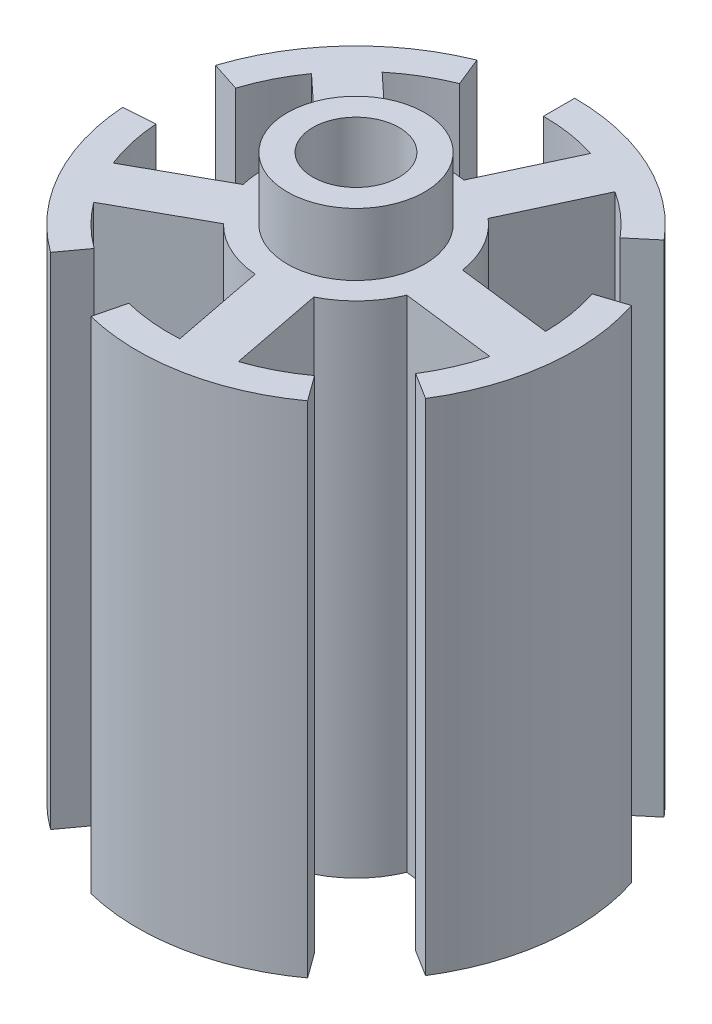
from build123d import *

# Parameters (mm, degrees)
BOSS_EXTRUDE2_DEPTH   = 40
BOSS_EXTRUDE2_2_DEPTH = 40
BOSS_EXTRUDE2_3_DEPTH = 40
BOSS_EXTRUDE2_4_DEPTH = 40
BOSS_EXTRUDE2_5_DEPTH = 40
BOSS_EXTRUDE3_DEPTH   = 40
SKETCH3_R             = 7.5
BOSS_EXTRUDE4_DEPTH   = 40
SKETCH5_R             = 5.5
BOSS_EXTRUDE5_DEPTH   = 5
SKETCH4_R             = 3.45
CUT_EXTRUDE1_DEPTH    = 45


with BuildPart() as part:
    # Sketch1 → Boss-Extrude2 (new body)
    with BuildSketch(Plane(origin=(0, 0, 0), x_dir=(1, 0, 0), z_dir=(0, 1, 0))):
        with BuildLine():
            Line((0, 17.5), (0, 15))
            ThreePointArc((0, 15), (6.339273926, 13.594616806), (11.490666647, 9.641814145))
            Line((11.490666647, 9.641814145), (13.405777755, 11.24878317))
            ThreePointArc((13.405777755, 11.24878317), (7.39581958, 15.860386273), (0, 17.5))
        make_face()
    extrude(amount=BOSS_EXTRUDE2_DEPTH)



with BuildPart() as body_2:
    # Sketch1 → Boss-Extrude2 2 (new body)
    with BuildSketch(Plane(origin=(0, 0, 0), x_dir=(1, 0, 0), z_dir=(0, 1, 0))):
        with BuildLine():
            Line((16.643489035, 5.407797402), (14.265847744, 4.635254916))
            ThreePointArc((14.265847744, 4.635254916), (14.888192275, -1.828040151), (12.720721442, -7.948788963))
            Line((12.720721442, -7.948788963), (14.840841683, -9.273587124))
            ThreePointArc((14.840841683, -9.273587124), (17.369557654, -2.13271351), (16.643489035, 5.407797402))
        make_face()
    extrude(amount=BOSS_EXTRUDE2_2_DEPTH)


with BuildPart() as body_3:
    # Sketch1 → Boss-Extrude2 3 (new body)
    with BuildSketch(Plane(origin=(0, 0, 0), x_dir=(1, 0, 0), z_dir=(0, 1, 0))):
        with BuildLine():
            Line((10.286241915, -14.157797402), (8.816778784, -12.135254916))
            ThreePointArc((8.816778784, -12.135254916), (2.862134931, -14.724407752), (-3.628828434, -14.554435894))
            Line((-3.628828434, -14.554435894), (-4.233633173, -16.98017521))
            ThreePointArc((-4.233633173, -16.98017521), (3.339157419, -17.17847571), (10.286241915, -14.157797402))
        make_face()
    extrude(amount=BOSS_EXTRUDE2_3_DEPTH)


with BuildPart() as body_4:
    # Sketch1 → Boss-Extrude2 4 (new body)
    with BuildSketch(Plane(origin=(0, 0, 0), x_dir=(1, 0, 0), z_dir=(0, 1, 0))):
        with BuildLine():
            Line((-10.286241915, -14.157797402), (-8.816778784, -12.135254916))
            ThreePointArc((-8.816778784, -12.135254916), (-13.119295607, -7.272144304), (-14.963460754, -1.046347106))
            Line((-14.963460754, -1.046347106), (-17.45737088, -1.220738291))
            ThreePointArc((-17.45737088, -1.220738291), (-15.305844875, -8.484168354), (-10.286241915, -14.157797402))
        make_face()
    extrude(amount=BOSS_EXTRUDE2_4_DEPTH)


with BuildPart() as body_5:
    # Sketch1 → Boss-Extrude2 5 (new body)
    with BuildSketch(Plane(origin=(0, 0, 0), x_dir=(1, 0, 0), z_dir=(0, 1, 0))):
        with BuildLine():
            Line((-16.643489035, 5.407797402), (-14.265847744, 4.635254916))
            ThreePointArc((-14.265847744, 4.635254916), (-10.970305524, 10.229975401), (-5.619098901, 13.907757819))
            Line((-5.619098901, 13.907757819), (-6.555615385, 16.225717455))
            ThreePointArc((-6.555615385, 16.225717455), (-12.798689778, 11.934971301), (-16.643489035, 5.407797402))
        make_face()
    extrude(amount=BOSS_EXTRUDE2_5_DEPTH)


with BuildPart() as part_1:
    add(part.part)

    add(body_2.part)  # Boss-Extrude3 merges body 2

    add(body_3.part)  # Boss-Extrude3 merges body 3

    add(body_4.part)  # Boss-Extrude3 merges body 4

    add(body_5.part)  # Boss-Extrude3 merges body 5
    # Sketch2 → Boss-Extrude3 (add)
    with BuildSketch(Plane(origin=(0, 0, 0), x_dir=(1, 0, 0), z_dir=(0, 1, 0))):
        Polygon((-1.438002264, -3.083805807), (0.898880564, -15.106025742), (4.825389298, -14.342789761), (2.48850647, -2.320569825), (14.644453588, -3.813132454), (15.131930961, 0.157052152), (2.975983844, 1.649614781), (8.1518895, 12.749380282), (4.526658352, 14.439853329), (-0.649247305, 3.340087828), (-9.606308804, 11.692682804), (-12.334302244, 8.767267998), (-3.377240745, 0.414673022), (-14.088914848, -5.522904889), (-12.149676367, -9.021383718), align=None)
        Polygon((-0.334260109, 0.311702594), (0.152686649, 0.084635592), (0.087207921, -0.448645859), align=None, mode=Mode.SUBTRACT)
    extrude(amount=BOSS_EXTRUDE3_DEPTH)

    # Sketch3 → Boss-Extrude4 (add)
    with BuildSketch(Plane(origin=(0, 0, 0), x_dir=(1, 0, 0), z_dir=(0, 1, 0))):
        Circle(SKETCH3_R)
    extrude(amount=BOSS_EXTRUDE4_DEPTH)

    # Sketch5 → Boss-Extrude5 (add)
    with BuildSketch(Plane(origin=(0, 40, 0), x_dir=(1, 0, 0), z_dir=(0, 1, 0))):
        Circle(SKETCH5_R)
    extrude(amount=BOSS_EXTRUDE5_DEPTH)

    # Sketch4 → Cut-Extrude1 (cut)
    with BuildSketch(Plane(origin=(0, 0, 0), x_dir=(1, 0, 0), z_dir=(0, 1, 0))):
        Circle(SKETCH4_R)
    extrude(amount=CUT_EXTRUDE1_DEPTH, mode=Mode.SUBTRACT)


solid = part_1.part
